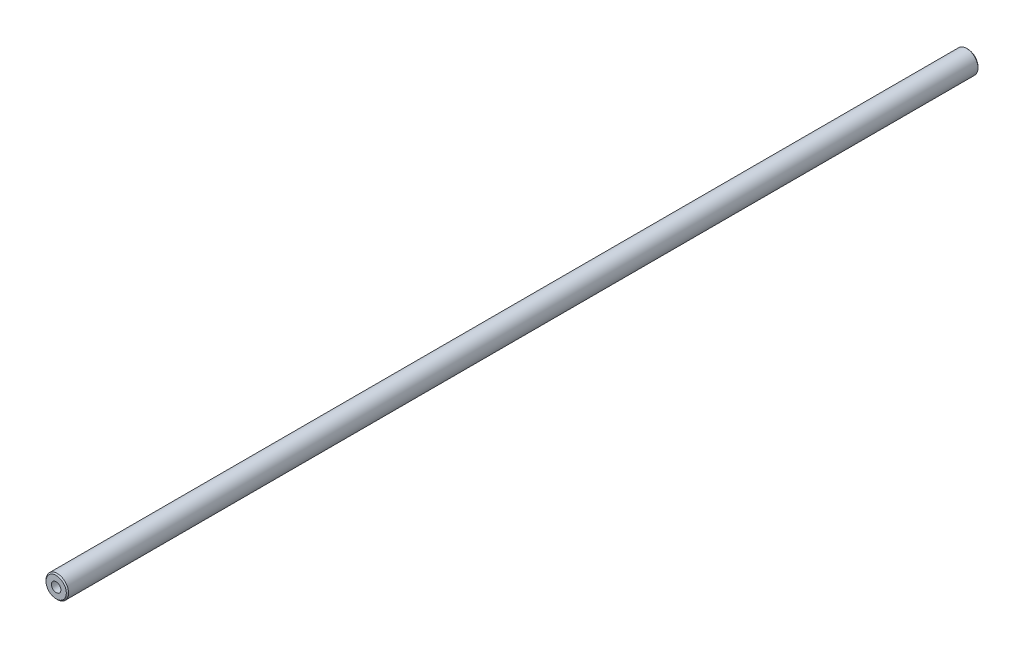
from build123d import *

# Parameters (mm, degrees)
SKETCH1_R                           = 5
BOSS_EXTRUDE1_DEPTH                 = 403.4811
CHAMFER1_SIZE                       = 0.5
M5X0_8_TAPPED_HOLE1_D               = 4.2
M5X0_8_TAPPED_HOLE1_DEPTH           = 16.4
M5X0_8_TAPPED_HOLE1_TIP             = 1.2618073
M5X0_8_TAPPED_HOLE1_ON_FACE_2_D     = 4.2
M5X0_8_TAPPED_HOLE1_ON_FACE_2_DEPTH = 16.4
M5X0_8_TAPPED_HOLE1_ON_FACE_2_TIP   = 1.2618073


with BuildPart() as part:
    # Sketch1 → Boss-Extrude1 (new body)
    with BuildSketch(Plane.XY):
        Circle(SKETCH1_R)
    extrude(amount=BOSS_EXTRUDE1_DEPTH)

    # Chamfer1
    chamfer1_edges = [part.edges().sort_by_distance(p)[0] for p in [
        (-5, 0, 0),
        (-5, 0, 403.4811),
    ]]
    chamfer(chamfer1_edges, length=CHAMFER1_SIZE)

    # M5x0.8 Tapped Hole1
    with Locations(Plane.XY.offset(403.4811)):
        with Locations((0, 0)):
            Hole(M5X0_8_TAPPED_HOLE1_D / 2, depth=M5X0_8_TAPPED_HOLE1_DEPTH)
            with Locations((0, 0, -(M5X0_8_TAPPED_HOLE1_DEPTH + M5X0_8_TAPPED_HOLE1_TIP / 2))):  # 118° drill point
                Cone(0, M5X0_8_TAPPED_HOLE1_D / 2, M5X0_8_TAPPED_HOLE1_TIP, mode=Mode.SUBTRACT)

    # M5x0.8 Tapped Hole1 on face 2
    with Locations(Plane(origin=(0, 0, 0), x_dir=(-1, 0, 0), z_dir=(0, 0, -1))):
        with Locations((0, 0)):
            Hole(M5X0_8_TAPPED_HOLE1_ON_FACE_2_D / 2, depth=M5X0_8_TAPPED_HOLE1_ON_FACE_2_DEPTH)
            with Locations((0, 0, -(M5X0_8_TAPPED_HOLE1_ON_FACE_2_DEPTH + M5X0_8_TAPPED_HOLE1_ON_FACE_2_TIP / 2))):  # 118° drill point
                Cone(0, M5X0_8_TAPPED_HOLE1_ON_FACE_2_D / 2, M5X0_8_TAPPED_HOLE1_ON_FACE_2_TIP, mode=Mode.SUBTRACT)


solid = part.part
